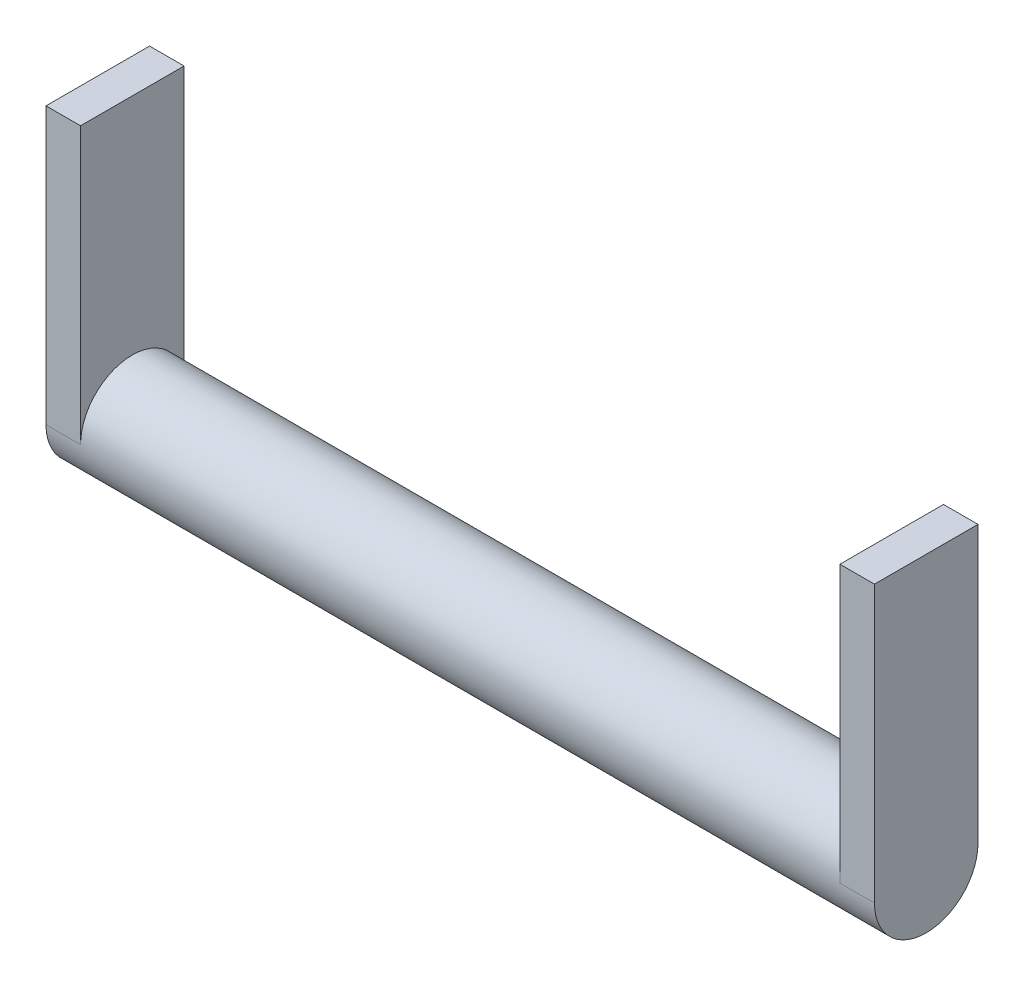
from build123d import *

# Parameters (mm, degrees)
SKETCH2_R           = 38.1
BOSS_EXTRUDE1_DEPTH = 279.4
BOSS_EXTRUDE2_DEPTH = 25.4


with BuildPart() as part:
    # Sketch2 → Boss-Extrude1 (new body)
    with BuildSketch(Plane(origin=(0, 0, 0), x_dir=(0, 0, -1), z_dir=(1, 0, 0))):
        Circle(SKETCH2_R)
    boss_extrude1 = extrude(amount=BOSS_EXTRUDE1_DEPTH)

    # Sketch3 → Boss-Extrude2 (add)
    with BuildSketch(Plane(origin=(279.4, 0, 0), x_dir=(0, 0, -1), z_dir=(1, 0, 0))):
        with BuildLine():
            Line((-38.1, 0), (-38.1, 203.2))
            Line((-38.1, 203.2), (38.1, 203.2))
            Line((38.1, 203.2), (38.1, 0))
            ThreePointArc((38.1, 0), (0, -38.1), (-38.1, 0))
        make_face()
    boss_extrude2 = extrude(amount=BOSS_EXTRUDE2_DEPTH)

    # Mirror1: Boss-Extrude1, Boss-Extrude2 across plane
    add(boss_extrude1.mirror(Plane(origin=(0, 0, 0), x_dir=(0, 0, 1), z_dir=(1, 0, 0))))
    add(boss_extrude2.mirror(Plane(origin=(0, 0, 0), x_dir=(0, 0, 1), z_dir=(1, 0, 0))))


solid = part.part
